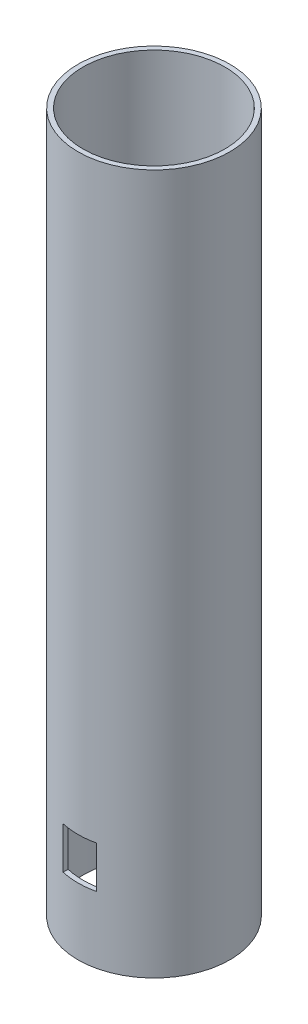
from build123d import *

# Parameters (mm, degrees)
SKETCH1_R               = 27.125
SKETCH1_R_2             = 25.375
BOSS_EXTRUDE1_DEPTH     = 125
SKETCH5_W               = 12
SKETCH5_H               = 15
CUT_EXTRUDE1_DEPTH      = 28.125
CUT_EXTRUDE1_DEPTH_BACK = 28.125


with BuildPart() as part:
    # Sketch1 → Boss-Extrude1 (new body, symmetric)
    with BuildSketch(Plane(origin=(0, 0, 0), x_dir=(1, 0, 0), z_dir=(0, 1, 0))):
        Circle(SKETCH1_R)
        Circle(SKETCH1_R_2, mode=Mode.SUBTRACT)
    extrude(amount=BOSS_EXTRUDE1_DEPTH, both=True)

    # Sketch5 → Cut-Extrude1 (cut, two sides)
    with BuildSketch(Plane.XY) as cut_extrude1_sk:
        with Locations((0, -93.7)):
            Rectangle(SKETCH5_W, SKETCH5_H)
    extrude(amount=CUT_EXTRUDE1_DEPTH, mode=Mode.SUBTRACT)
    extrude(cut_extrude1_sk.sketch, amount=-CUT_EXTRUDE1_DEPTH_BACK, mode=Mode.SUBTRACT)


solid = part.part
